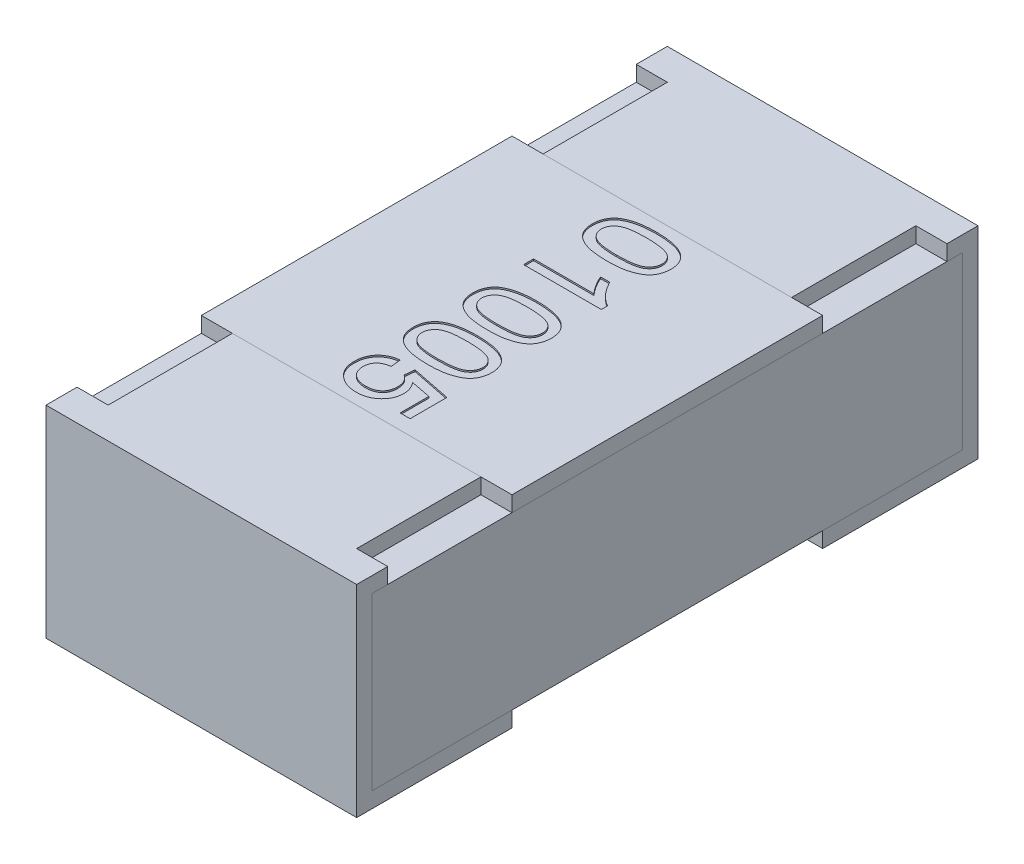
from build123d import *

# Parameters (mm, degrees)
BOSS_EXTRUDE2_DEPTH   = 0.1
BOSS_EXTRUDE2_2_DEPTH = 0.1
BOSS_EXTRUDE3_START   = -0.1
SKETCH5_W             = 0.38
SKETCH5_H             = 0.11
BOSS_EXTRUDE3_DEPTH   = 0.2
SKETCH6_W             = 0.02
SKETCH6_H             = 0.08
CUT_EXTRUDE1_DEPTH    = 0.01
SKETCH7_W             = 0.2
SKETCH7_H             = 0.2
BOSS_EXTRUDE4_DEPTH   = 0.01
TEXT01005_DEPTH       = 0.001


with BuildPart() as part:
    # Sketch4 → Boss-Extrude2 (new, symmetric)
    with BuildSketch(Plane(origin=(0, 0, 0), x_dir=(0, 0, -1), z_dir=(1, 0, 0))):
        Polygon((-0.2, 0.065), (-0.2, -0.065), (-0.1, -0.065), (-0.1, -0.055), (-0.19, -0.055), (-0.19, 0.055), (-0.1, 0.055), (-0.1, 0.065), align=None)
    extrude(amount=BOSS_EXTRUDE2_DEPTH, both=True)


with BuildPart() as body_2:
    # Sketch4 → Boss-Extrude2 2 (new, symmetric)
    with BuildSketch(Plane(origin=(0, 0, 0), x_dir=(0, 0, -1), z_dir=(1, 0, 0))):
        Polygon((0.1, 0.065), (0.2, 0.065), (0.2, -0.065), (0.1, -0.065), (0.1, -0.055), (0.19, -0.055), (0.19, 0.055), (0.1, 0.055), align=None)
    extrude(amount=BOSS_EXTRUDE2_2_DEPTH, both=True)


with BuildPart() as body_3:
    # Sketch5 → Boss-Extrude3 (new body)
    with BuildSketch(Plane(origin=(0, 0, 0), x_dir=(0, 0, -1), z_dir=(1, 0, 0)).offset(BOSS_EXTRUDE3_START)):
        Rectangle(SKETCH5_W, SKETCH5_H)
    extrude(amount=BOSS_EXTRUDE3_DEPTH)


with BuildPart() as cut_extrude1_tool:
    # Sketch6 → Cut-Extrude1 (new body)
    with BuildSketch(Plane(origin=(0, 0.065, 0), x_dir=(1, 0, 0), z_dir=(0, 1, 0))):
        with Locations((-0.09, 0.14)):
            Rectangle(SKETCH6_W, SKETCH6_H)
        with Locations((0.09, 0.14)):
            Rectangle(SKETCH6_W, SKETCH6_H)
        with Locations((0.09, -0.14)):
            Rectangle(SKETCH6_W, SKETCH6_H)
        with Locations((-0.09, -0.14)):
            Rectangle(SKETCH6_W, SKETCH6_H)
    extrude(amount=-CUT_EXTRUDE1_DEPTH)


with BuildPart() as part_1:
    add(part.part)

    # Cut-Extrude1: cut by cut_extrude1_tool
    add(cut_extrude1_tool.part, mode=Mode.SUBTRACT)


with BuildPart() as body_2_1:
    add(body_2.part)

    # Cut-Extrude1: cut by cut_extrude1_tool
    add(cut_extrude1_tool.part, mode=Mode.SUBTRACT)


with BuildPart() as body_4:
    # Sketch7 → Boss-Extrude4 (new body)
    with BuildSketch(Plane(origin=(0, 0.055, 0), x_dir=(1, 0, 0), z_dir=(0, 1, 0))):
        Rectangle(SKETCH7_W, SKETCH7_H)
    extrude(amount=BOSS_EXTRUDE4_DEPTH)

    # PART NUMBER → TEXT01005 (cut)
    with BuildSketch(Plane(origin=(0, 0.065, 0), x_dir=(1, 0, 0), z_dir=(0, 1, 0))):
        with BuildLine():
            add(Edge.make_bspline(
                [(8.8495e-05, 0.092948718), (0.000803041, 0.09294226), (0.002202536, 0.09292961), (0.004250247, 0.092851152), (0.006194875, 0.092714169), (0.008034729, 0.092509693), (0.00977396, 0.092267551), (0.011410096, 0.091952778), (0.012946776, 0.091598571), (0.014382506, 0.091173731), (0.015729255, 0.090706481), (0.016986174, 0.090178088), (0.018145829, 0.08957835), (0.019239713, 0.088961347), (0.020216586, 0.088242997), (0.021138322, 0.087514504), (0.021952307, 0.08670136), (0.022685184, 0.08584224), (0.023331701, 0.084922905), (0.023889621, 0.083948635), (0.024382209, 0.082923069), (0.024753033, 0.08182669), (0.025055332, 0.080682251), (0.025277707, 0.079480944), (0.025408805, 0.078221446), (0.025422219, 0.077360756), (0.02542904, 0.076923077)],
                knots=[0, 0, 0, 0, 1.514715004, 2.966688829, 4.343277319, 5.646155648, 6.890271291, 8.064567311, 9.176982507, 10.231801866, 11.236819303, 12.197732759, 13.118802951, 14.00370591, 14.856056722, 15.686168072, 16.491905873, 17.290274347, 18.077650358, 18.870352107, 19.668187111, 20.485160842, 21.319455353, 22.17593919, 23.072426909, 24, 24, 24, 24], degree=3))
            add(Edge.make_bspline(
                [(0.02542904, 0.076923077), (0.025410145, 0.076280957), (0.025373025, 0.075019485), (0.025070789, 0.073177535), (0.024552489, 0.071442361), (0.023858738, 0.069814235), (0.022961316, 0.068328362), (0.021898424, 0.066984995), (0.020625562, 0.065838411), (0.0191845, 0.064850736), (0.017572378, 0.064003804), (0.015804378, 0.06324619), (0.013873004, 0.062566917), (0.012149052, 0.06206972), (0.010658354, 0.06172114), (0.009426545, 0.061508915), (0.008101495, 0.06131297), (0.006680033, 0.061174081), (0.005168803, 0.061032751), (0.003561213, 0.060962974), (0.001858357, 0.060909724), (0.000689509, 0.060901609), (8.8495e-05, 0.060897436)],
                knots=[0, 0, 0, 0, 1.134508601, 2.228787654, 3.287419779, 4.328790846, 5.347871456, 6.346850563, 7.345149742, 8.363256079, 9.427154287, 10.558404831, 11.760335901, 13.043439251, 13.7276639, 14.464993199, 15.251939769, 16.09452972, 16.988861801, 17.934185368, 18.937772297, 20, 20, 20, 20], degree=3))
            add(Edge.make_bspline(
                [(8.8495e-05, 0.060897436), (-0.0006227, 0.060903979), (-0.00201216, 0.060916762), (-0.004043374, 0.060993624), (-0.005973605, 0.06113708), (-0.007805205, 0.061321944), (-0.009539873, 0.06157084), (-0.011173365, 0.061881931), (-0.012707682, 0.062241242), (-0.014144374, 0.062647851), (-0.015485416, 0.063120912), (-0.016737228, 0.063654462), (-0.017912074, 0.064226585), (-0.018988075, 0.064875528), (-0.019983042, 0.065566691), (-0.020900108, 0.066306531), (-0.021726238, 0.067110372), (-0.022456707, 0.067977512), (-0.023114851, 0.068890284), (-0.023677844, 0.069867085), (-0.024147521, 0.070905631), (-0.024540072, 0.071996665), (-0.024838402, 0.073147429), (-0.025059905, 0.074351926), (-0.025192206, 0.075618016), (-0.025205301, 0.076482055), (-0.025211986, 0.076923077)],
                knots=[0, 0, 0, 0, 1.50892112, 2.947974422, 4.311604492, 5.614840882, 6.853004102, 8.028299315, 9.14166105, 10.195403725, 11.194594867, 12.156325951, 13.08133133, 13.964490992, 14.819271038, 15.650088719, 16.461567135, 17.260614929, 18.05275699, 18.846133239, 19.648095618, 20.468123593, 21.303127994, 22.167306962, 23.06455749, 24, 24, 24, 24], degree=3))
            add(Edge.make_bspline(
                [(-0.025211986, 0.076923077), (-0.025195492, 0.077501295), (-0.025163334, 0.078628662), (-0.024944839, 0.080275097), (-0.024560277, 0.081820365), (-0.024044526, 0.083277498), (-0.023354678, 0.084630119), (-0.022515345, 0.085884684), (-0.021546052, 0.087066404), (-0.020781303, 0.087746674), (-0.020394277, 0.088090946)],
                knots=[0, 0, 0, 0, 1.10322584, 2.150986741, 3.161425019, 4.136713905, 5.093944212, 6.049774532, 7.013026876, 8, 8, 8, 8], degree=3))
            add(Edge.make_bspline(
                [(-0.020394277, 0.088090946), (-0.019822659, 0.088487211), (-0.018643958, 0.089304326), (-0.016634164, 0.090260689), (-0.014421662, 0.091113781), (-0.011963045, 0.091783302), (-0.009277879, 0.092307704), (-0.006360896, 0.092686453), (-0.003213356, 0.092900788), (-0.001036968, 0.092932381), (8.8495e-05, 0.092948718)],
                knots=[0, 0, 0, 0, 0.779365345, 1.607084704, 2.489375761, 3.438383567, 4.461919411, 5.557722155, 6.737039282, 8, 8, 8, 8], degree=3))
        make_face()
        with BuildLine():
            add(Edge.make_bspline(
                [(0.000108527, 0.086538462), (-0.000853155, 0.086532097), (-0.002694026, 0.086519913), (-0.005324029, 0.086392622), (-0.007696651, 0.086173496), (-0.009808606, 0.085883797), (-0.011662752, 0.085501277), (-0.013254364, 0.085020978), (-0.014602544, 0.084479567), (-0.015690582, 0.083809581), (-0.016577493, 0.08307602), (-0.017340264, 0.082318668), (-0.017988602, 0.081519709), (-0.018529184, 0.080684353), (-0.018938478, 0.079799642), (-0.019235134, 0.078875248), (-0.019405855, 0.07791097), (-0.019430385, 0.077254254), (-0.019442755, 0.076923077)],
                knots=[0, 0, 0, 0, 1.89448813, 3.626469325, 5.185477471, 6.587276848, 7.82441448, 8.910550357, 9.859733512, 10.6775885, 11.416198291, 12.123144072, 12.791880183, 13.439617036, 14.078171869, 14.70637855, 15.347637704, 16, 16, 16, 16], degree=3))
            add(Edge.make_bspline(
                [(-0.019442755, 0.076923077), (-0.019430115, 0.076591983), (-0.019405049, 0.075935431), (-0.019238092, 0.074968925), (-0.018926164, 0.074048128), (-0.018518317, 0.073164736), (-0.017990056, 0.072323309), (-0.017339269, 0.071528273), (-0.01657695, 0.070766932), (-0.015679731, 0.070036666), (-0.014586662, 0.069371784), (-0.01323958, 0.068820217), (-0.011645182, 0.068347403), (-0.009791981, 0.067962784), (-0.007683364, 0.06767189), (-0.005317323, 0.067454089), (-0.002690704, 0.067325946), (-0.000853159, 0.067313964), (0.000108527, 0.067307692)],
                knots=[0, 0, 0, 0, 0.652509534, 1.29391342, 1.924290653, 2.562989607, 3.207355802, 3.876242846, 4.583348185, 5.32723334, 6.150888545, 7.094226006, 8.186903555, 9.424320409, 10.81992305, 12.379283064, 14.105084285, 16, 16, 16, 16], degree=3))
            add(Edge.make_bspline(
                [(0.000108527, 0.067307692), (0.001050204, 0.067313763), (0.002854421, 0.067325393), (0.005433756, 0.067456842), (0.007766557, 0.067662829), (0.009854958, 0.067944602), (0.011696748, 0.06831903), (0.013295668, 0.068773305), (0.014648865, 0.0693142), (0.01576821, 0.06995868), (0.016692192, 0.07067326), (0.017476382, 0.071432482), (0.018163594, 0.072221654), (0.018701695, 0.073085875), (0.019143015, 0.073988405), (0.019438449, 0.074948591), (0.019628057, 0.075954035), (0.01964907, 0.076641738), (0.019659809, 0.076993189)],
                knots=[0, 0, 0, 0, 1.850145643, 3.544809038, 5.072983816, 6.450691362, 7.683229814, 8.76276662, 9.712991103, 10.538891656, 11.292051756, 12.001912283, 12.681449089, 13.342071824, 13.996410874, 14.649960216, 15.310061595, 16, 16, 16, 16], degree=3))
            add(Edge.make_bspline(
                [(0.019659809, 0.076993189), (0.019651118, 0.077324345), (0.019633979, 0.077977342), (0.019470391, 0.078933415), (0.019196836, 0.079839474), (0.018826279, 0.0807059), (0.018327583, 0.081511063), (0.01774532, 0.082286893), (0.017035896, 0.082997054), (0.016505543, 0.08342499), (0.016234329, 0.08364383)],
                knots=[0, 0, 0, 0, 1.021318143, 2.013908504, 2.982026795, 3.937174072, 4.91255697, 5.897578595, 6.924855925, 8, 8, 8, 8], degree=3))
            add(Edge.make_bspline(
                [(0.016234329, 0.08364383), (0.015835999, 0.08388208), (0.01499481, 0.084385213), (0.01353279, 0.084948191), (0.011861979, 0.085445502), (0.009956671, 0.085854955), (0.007820135, 0.086151165), (0.00545485, 0.086385011), (0.002857516, 0.086506486), (0.001050139, 0.086527509), (0.000108527, 0.086538462)],
                knots=[0, 0, 0, 0, 0.671104906, 1.417232262, 2.260109084, 3.195198885, 4.23592645, 5.382417421, 6.636286093, 8, 8, 8, 8], degree=3))
        make_face(mode=Mode.SUBTRACT)
        with BuildLine():
            Line((-0.02457096, 0.032051282), (-0.02457096, 0.038461538))
            Line((-0.02457096, 0.038461538), (0.01439138, 0.038461538))
            add(Edge.make_bspline(
                [(0.01439138, 0.038461538), (0.014035458, 0.038830663), (0.013295714, 0.039597847), (0.012248134, 0.040894257), (0.011190981, 0.042340899), (0.010160607, 0.043913775), (0.009209622, 0.045529431), (0.008341859, 0.047086025), (0.007611299, 0.048561816), (0.007211452, 0.049533661), (0.007019585, 0.05)],
                knots=[0, 0, 0, 0, 0.89334793, 1.85672577, 2.901900665, 4.015525414, 5.132247281, 6.168817625, 7.121308293, 8, 8, 8, 8], degree=3))
            Line((0.007019585, 0.05), (0.01292904, 0.05))
            add(Edge.make_bspline(
                [(0.01292904, 0.05), (0.013341567, 0.04919898), (0.014154633, 0.047620217), (0.01555891, 0.045389766), (0.017081204, 0.0433074), (0.018721178, 0.041407591), (0.020397526, 0.039704533), (0.022089027, 0.038269341), (0.023733678, 0.037068464), (0.02488064, 0.036465961), (0.02542904, 0.036177885)],
                knots=[0, 0, 0, 0, 1.141258006, 2.249351951, 3.335817539, 4.406819942, 5.426913362, 6.360259544, 7.215985427, 8, 8, 8, 8], degree=3))
            Line((0.02542904, 0.036177885), (0.02542904, 0.032051282))
            Line((0.02542904, 0.032051282), (-0.02457096, 0.032051282))
        make_face()
        with BuildLine():
            add(Edge.make_bspline(
                [(8.8495e-05, 0.016025641), (0.000803041, 0.016019183), (0.002202536, 0.016006534), (0.004250247, 0.015928075), (0.006194875, 0.015791092), (0.008034729, 0.015586616), (0.00977396, 0.015344474), (0.011410096, 0.015029701), (0.012946776, 0.014675494), (0.014382506, 0.014250654), (0.015729255, 0.013783404), (0.016986174, 0.013255012), (0.018145829, 0.012655273), (0.019239713, 0.01203827), (0.020216586, 0.01131992), (0.021138322, 0.010591427), (0.021952307, 0.009778283), (0.022685184, 0.008919163), (0.023331701, 0.007999828), (0.023889621, 0.007025559), (0.024382209, 0.005999992), (0.024753033, 0.004903613), (0.025055332, 0.003759174), (0.025277707, 0.002557867), (0.025408805, 0.001298369), (0.025422219, 0.000437679), (0.02542904, 0)],
                knots=[0, 0, 0, 0, 1.514715004, 2.966688829, 4.343277319, 5.646155648, 6.890271291, 8.064567311, 9.176982507, 10.231801866, 11.236819303, 12.197732759, 13.118802951, 14.00370591, 14.856056722, 15.686168072, 16.491905873, 17.290274347, 18.077650358, 18.870352107, 19.668187111, 20.485160842, 21.319455353, 22.17593919, 23.072426909, 24, 24, 24, 24], degree=3))
            add(Edge.make_bspline(
                [(0.02542904, 0), (0.025410145, -0.00064212), (0.025373025, -0.001903592), (0.025070789, -0.003745542), (0.024552489, -0.005480716), (0.023858738, -0.007108842), (0.022961316, -0.008594715), (0.021898424, -0.009938082), (0.020625562, -0.011084666), (0.0191845, -0.012072341), (0.017572378, -0.012919273), (0.015804378, -0.013676887), (0.013873004, -0.014356159), (0.012149052, -0.014853357), (0.010658354, -0.015201937), (0.009426545, -0.015414162), (0.008101495, -0.015610107), (0.006680033, -0.015748996), (0.005168803, -0.015890326), (0.003561213, -0.015960103), (0.001858357, -0.016013353), (0.000689509, -0.016021468), (8.8495e-05, -0.016025641)],
                knots=[0, 0, 0, 0, 1.134508601, 2.228787654, 3.287419779, 4.328790846, 5.347871456, 6.346850563, 7.345149742, 8.363256079, 9.427154287, 10.558404831, 11.760335901, 13.043439251, 13.7276639, 14.464993199, 15.251939769, 16.09452972, 16.988861801, 17.934185368, 18.937772297, 20, 20, 20, 20], degree=3))
            add(Edge.make_bspline(
                [(8.8495e-05, -0.016025641), (-0.0006227, -0.016019098), (-0.00201216, -0.016006315), (-0.004043374, -0.015929453), (-0.005973605, -0.015785997), (-0.007805205, -0.015601133), (-0.009539873, -0.015352237), (-0.011173365, -0.015041146), (-0.012707682, -0.014681835), (-0.014144374, -0.014275226), (-0.015485416, -0.013802165), (-0.016737228, -0.013268615), (-0.017912074, -0.012696492), (-0.018988075, -0.012047549), (-0.019983042, -0.011356386), (-0.020900108, -0.010616546), (-0.021726238, -0.009812705), (-0.022456707, -0.008945565), (-0.023114851, -0.008032793), (-0.023677844, -0.007055991), (-0.024147521, -0.006017446), (-0.024540072, -0.004926412), (-0.024838402, -0.003775648), (-0.025059905, -0.00257115), (-0.025192206, -0.001305061), (-0.025205301, -0.000441022), (-0.025211986, 0)],
                knots=[0, 0, 0, 0, 1.50892112, 2.947974422, 4.311604492, 5.614840882, 6.853004102, 8.028299315, 9.14166105, 10.195403725, 11.194594867, 12.156325951, 13.08133133, 13.964490992, 14.819271038, 15.650088719, 16.461567135, 17.260614929, 18.05275699, 18.846133239, 19.648095618, 20.468123593, 21.303127994, 22.167306962, 23.06455749, 24, 24, 24, 24], degree=3))
            add(Edge.make_bspline(
                [(-0.025211986, 0), (-0.025195492, 0.000578218), (-0.025163334, 0.001705585), (-0.024944839, 0.003352021), (-0.024560277, 0.004897288), (-0.024044526, 0.006354421), (-0.023354678, 0.007707042), (-0.022515345, 0.008961607), (-0.021546052, 0.010143327), (-0.020781303, 0.010823597), (-0.020394277, 0.011167869)],
                knots=[0, 0, 0, 0, 1.10322584, 2.150986741, 3.161425019, 4.136713905, 5.093944212, 6.049774532, 7.013026876, 8, 8, 8, 8], degree=3))
            add(Edge.make_bspline(
                [(-0.020394277, 0.011167869), (-0.019822659, 0.011564134), (-0.018643958, 0.012381249), (-0.016634164, 0.013337612), (-0.014421662, 0.014190704), (-0.011963045, 0.014860225), (-0.009277879, 0.015384627), (-0.006360896, 0.015763377), (-0.003213356, 0.015977711), (-0.001036968, 0.016009304), (8.8495e-05, 0.016025641)],
                knots=[0, 0, 0, 0, 0.779365345, 1.607084704, 2.489375761, 3.438383567, 4.461919411, 5.557722155, 6.737039282, 8, 8, 8, 8], degree=3))
        make_face()
        with BuildLine():
            add(Edge.make_bspline(
                [(0.000108527, 0.009615385), (-0.000853155, 0.00960902), (-0.002694026, 0.009596836), (-0.005324029, 0.009469545), (-0.007696651, 0.009250419), (-0.009808606, 0.00896072), (-0.011662752, 0.0085782), (-0.013254364, 0.008097901), (-0.014602544, 0.00755649), (-0.015690582, 0.006886504), (-0.016577493, 0.006152943), (-0.017340264, 0.005395592), (-0.017988602, 0.004596632), (-0.018529184, 0.003761276), (-0.018938478, 0.002876565), (-0.019235134, 0.001952171), (-0.019405855, 0.000987893), (-0.019430385, 0.000331177), (-0.019442755, 0)],
                knots=[0, 0, 0, 0, 1.89448813, 3.626469325, 5.185477471, 6.587276848, 7.82441448, 8.910550357, 9.859733512, 10.6775885, 11.416198291, 12.123144072, 12.791880183, 13.439617036, 14.078171869, 14.70637855, 15.347637704, 16, 16, 16, 16], degree=3))
            add(Edge.make_bspline(
                [(-0.019442755, 0), (-0.019430115, -0.000331094), (-0.019405049, -0.000987646), (-0.019238092, -0.001954151), (-0.018926164, -0.002874949), (-0.018518317, -0.003758341), (-0.017990056, -0.004599768), (-0.017339269, -0.005394804), (-0.01657695, -0.006156145), (-0.015679731, -0.006886411), (-0.014586662, -0.007551293), (-0.01323958, -0.00810286), (-0.011645182, -0.008575674), (-0.009791981, -0.008960293), (-0.007683364, -0.009251187), (-0.005317323, -0.009468988), (-0.002690704, -0.009597131), (-0.000853159, -0.009609113), (0.000108527, -0.009615385)],
                knots=[0, 0, 0, 0, 0.652509534, 1.29391342, 1.924290653, 2.562989607, 3.207355802, 3.876242846, 4.583348185, 5.32723334, 6.150888545, 7.094226006, 8.186903555, 9.424320409, 10.81992305, 12.379283064, 14.105084285, 16, 16, 16, 16], degree=3))
            add(Edge.make_bspline(
                [(0.000108527, -0.009615385), (0.001050204, -0.009609314), (0.002854421, -0.009597684), (0.005433756, -0.009466235), (0.007766557, -0.009260248), (0.009854958, -0.008978475), (0.011696748, -0.008604047), (0.013295668, -0.008149772), (0.014648865, -0.007608877), (0.01576821, -0.006964396), (0.016692192, -0.006249817), (0.017476382, -0.005490595), (0.018163594, -0.004701423), (0.018701695, -0.003837202), (0.019143015, -0.002934672), (0.019438449, -0.001974486), (0.019628057, -0.000969042), (0.01964907, -0.000281339), (0.019659809, 7.0112e-05)],
                knots=[0, 0, 0, 0, 1.850145643, 3.544809038, 5.072983816, 6.450691362, 7.683229814, 8.76276662, 9.712991103, 10.538891656, 11.292051756, 12.001912283, 12.681449089, 13.342071824, 13.996410874, 14.649960216, 15.310061595, 16, 16, 16, 16], degree=3))
            add(Edge.make_bspline(
                [(0.019659809, 7.0112e-05), (0.019651118, 0.000401268), (0.019633979, 0.001054265), (0.019470391, 0.002010338), (0.019196836, 0.002916397), (0.018826279, 0.003782823), (0.018327583, 0.004587986), (0.01774532, 0.005363816), (0.017035896, 0.006073977), (0.016505543, 0.006501913), (0.016234329, 0.006720753)],
                knots=[0, 0, 0, 0, 1.021318143, 2.013908504, 2.982026795, 3.937174072, 4.91255697, 5.897578595, 6.924855925, 8, 8, 8, 8], degree=3))
            add(Edge.make_bspline(
                [(0.016234329, 0.006720753), (0.015835999, 0.006959003), (0.01499481, 0.007462137), (0.01353279, 0.008025114), (0.011861979, 0.008522425), (0.009956671, 0.008931878), (0.007820135, 0.009228088), (0.00545485, 0.009461934), (0.002857516, 0.009583409), (0.001050139, 0.009604432), (0.000108527, 0.009615385)],
                knots=[0, 0, 0, 0, 0.671104906, 1.417232262, 2.260109084, 3.195198885, 4.23592645, 5.382417421, 6.636286093, 8, 8, 8, 8], degree=3))
        make_face(mode=Mode.SUBTRACT)
        with BuildLine():
            add(Edge.make_bspline(
                [(8.8495e-05, -0.022435897), (0.000803041, -0.022442356), (0.002202536, -0.022455005), (0.004250247, -0.022533463), (0.006194875, -0.022670446), (0.008034729, -0.022874922), (0.00977396, -0.023117064), (0.011410096, -0.023431837), (0.012946776, -0.023786044), (0.014382506, -0.024210885), (0.015729255, -0.024678134), (0.016986174, -0.025206527), (0.018145829, -0.025806265), (0.019239713, -0.026423269), (0.020216586, -0.027141619), (0.021138322, -0.027870112), (0.021952307, -0.028683255), (0.022685184, -0.029542375), (0.023331701, -0.03046171), (0.023889621, -0.03143598), (0.024382209, -0.032461546), (0.024753033, -0.033557925), (0.025055332, -0.034702365), (0.025277707, -0.035903671), (0.025408805, -0.037163169), (0.025422219, -0.03802386), (0.02542904, -0.038461538)],
                knots=[0, 0, 0, 0, 1.514715004, 2.966688829, 4.343277319, 5.646155648, 6.890271291, 8.064567311, 9.176982507, 10.231801866, 11.236819303, 12.197732759, 13.118802951, 14.00370591, 14.856056722, 15.686168072, 16.491905873, 17.290274347, 18.077650358, 18.870352107, 19.668187111, 20.485160842, 21.319455353, 22.17593919, 23.072426909, 24, 24, 24, 24], degree=3))
            add(Edge.make_bspline(
                [(0.02542904, -0.038461538), (0.025410145, -0.039103659), (0.025373025, -0.04036513), (0.025070789, -0.042207081), (0.024552489, -0.043942255), (0.023858738, -0.045570381), (0.022961316, -0.047056253), (0.021898424, -0.048399621), (0.020625562, -0.049546205), (0.0191845, -0.05053388), (0.017572378, -0.051380811), (0.015804378, -0.052138426), (0.013873004, -0.052817698), (0.012149052, -0.053314896), (0.010658354, -0.053663475), (0.009426545, -0.0538757), (0.008101495, -0.054071646), (0.006680033, -0.054210534), (0.005168803, -0.054351865), (0.003561213, -0.054421641), (0.001858357, -0.054474891), (0.000689509, -0.054483007), (8.8495e-05, -0.054487179)],
                knots=[0, 0, 0, 0, 1.134508601, 2.228787654, 3.287419779, 4.328790846, 5.347871456, 6.346850563, 7.345149742, 8.363256079, 9.427154287, 10.558404831, 11.760335901, 13.043439251, 13.7276639, 14.464993199, 15.251939769, 16.09452972, 16.988861801, 17.934185368, 18.937772297, 20, 20, 20, 20], degree=3))
            add(Edge.make_bspline(
                [(8.8495e-05, -0.054487179), (-0.0006227, -0.054480637), (-0.00201216, -0.054467854), (-0.004043374, -0.054390992), (-0.005973605, -0.054247536), (-0.007805205, -0.054062672), (-0.009539873, -0.053813776), (-0.011173365, -0.053502685), (-0.012707682, -0.053143374), (-0.014144374, -0.052736764), (-0.015485416, -0.052263704), (-0.016737228, -0.051730154), (-0.017912074, -0.051158031), (-0.018988075, -0.050509088), (-0.019983042, -0.049817925), (-0.020900108, -0.049078085), (-0.021726238, -0.048274243), (-0.022456707, -0.047407104), (-0.023114851, -0.046494332), (-0.023677844, -0.04551753), (-0.024147521, -0.044478984), (-0.024540072, -0.04338795), (-0.024838402, -0.042237187), (-0.025059905, -0.041032689), (-0.025192206, -0.039766599), (-0.025205301, -0.038902561), (-0.025211986, -0.038461538)],
                knots=[0, 0, 0, 0, 1.50892112, 2.947974422, 4.311604492, 5.614840882, 6.853004102, 8.028299315, 9.14166105, 10.195403725, 11.194594867, 12.156325951, 13.08133133, 13.964490992, 14.819271038, 15.650088719, 16.461567135, 17.260614929, 18.05275699, 18.846133239, 19.648095618, 20.468123593, 21.303127994, 22.167306962, 23.06455749, 24, 24, 24, 24], degree=3))
            add(Edge.make_bspline(
                [(-0.025211986, -0.038461538), (-0.025195492, -0.03788332), (-0.025163334, -0.036755954), (-0.024944839, -0.035109518), (-0.024560277, -0.03356425), (-0.024044526, -0.032107117), (-0.023354678, -0.030754497), (-0.022515345, -0.029499932), (-0.021546052, -0.028318212), (-0.020781303, -0.027637942), (-0.020394277, -0.02729367)],
                knots=[0, 0, 0, 0, 1.10322584, 2.150986741, 3.161425019, 4.136713905, 5.093944212, 6.049774532, 7.013026876, 8, 8, 8, 8], degree=3))
            add(Edge.make_bspline(
                [(-0.020394277, -0.02729367), (-0.019822659, -0.026897405), (-0.018643958, -0.026080289), (-0.016634164, -0.025123927), (-0.014421662, -0.024270834), (-0.011963045, -0.023601313), (-0.009277879, -0.023076911), (-0.006360896, -0.022698162), (-0.003213356, -0.022483827), (-0.001036968, -0.022452235), (8.8495e-05, -0.022435897)],
                knots=[0, 0, 0, 0, 0.779365345, 1.607084704, 2.489375761, 3.438383567, 4.461919411, 5.557722155, 6.737039282, 8, 8, 8, 8], degree=3))
        make_face()
        with BuildLine():
            add(Edge.make_bspline(
                [(0.000108527, -0.028846154), (-0.000853155, -0.028852519), (-0.002694026, -0.028864702), (-0.005324029, -0.028991993), (-0.007696651, -0.029211119), (-0.009808606, -0.029500818), (-0.011662752, -0.029883338), (-0.013254364, -0.030363637), (-0.014602544, -0.030905049), (-0.015690582, -0.031575035), (-0.016577493, -0.032308596), (-0.017340264, -0.033065947), (-0.017988602, -0.033864907), (-0.018529184, -0.034700262), (-0.018938478, -0.035584974), (-0.019235134, -0.036509368), (-0.019405855, -0.037473645), (-0.019430385, -0.038130362), (-0.019442755, -0.038461538)],
                knots=[0, 0, 0, 0, 1.89448813, 3.626469325, 5.185477471, 6.587276848, 7.82441448, 8.910550357, 9.859733512, 10.6775885, 11.416198291, 12.123144072, 12.791880183, 13.439617036, 14.078171869, 14.70637855, 15.347637704, 16, 16, 16, 16], degree=3))
            add(Edge.make_bspline(
                [(-0.019442755, -0.038461538), (-0.019430115, -0.038792632), (-0.019405049, -0.039449184), (-0.019238092, -0.04041569), (-0.018926164, -0.041336487), (-0.018518317, -0.04221988), (-0.017990056, -0.043061307), (-0.017339269, -0.043856343), (-0.01657695, -0.044617684), (-0.015679731, -0.045347949), (-0.014586662, -0.046012831), (-0.01323958, -0.046564398), (-0.011645182, -0.047037212), (-0.009791981, -0.047421831), (-0.007683364, -0.047712725), (-0.005317323, -0.047930526), (-0.002690704, -0.048058669), (-0.000853159, -0.048070652), (0.000108527, -0.048076923)],
                knots=[0, 0, 0, 0, 0.652509534, 1.29391342, 1.924290653, 2.562989607, 3.207355802, 3.876242846, 4.583348185, 5.32723334, 6.150888545, 7.094226006, 8.186903555, 9.424320409, 10.81992305, 12.379283064, 14.105084285, 16, 16, 16, 16], degree=3))
            add(Edge.make_bspline(
                [(0.000108527, -0.048076923), (0.001050204, -0.048070853), (0.002854421, -0.048059222), (0.005433756, -0.047927773), (0.007766557, -0.047721786), (0.009854958, -0.047440014), (0.011696748, -0.047065585), (0.013295668, -0.046611311), (0.014648865, -0.046070415), (0.01576821, -0.045425935), (0.016692192, -0.044711356), (0.017476382, -0.043952134), (0.018163594, -0.043162961), (0.018701695, -0.04229874), (0.019143015, -0.041396211), (0.019438449, -0.040436025), (0.019628057, -0.03943058), (0.01964907, -0.038742877), (0.019659809, -0.038391426)],
                knots=[0, 0, 0, 0, 1.850145643, 3.544809038, 5.072983816, 6.450691362, 7.683229814, 8.76276662, 9.712991103, 10.538891656, 11.292051756, 12.001912283, 12.681449089, 13.342071824, 13.996410874, 14.649960216, 15.310061595, 16, 16, 16, 16], degree=3))
            add(Edge.make_bspline(
                [(0.019659809, -0.038391426), (0.019651118, -0.03806027), (0.019633979, -0.037407273), (0.019470391, -0.0364512), (0.019196836, -0.035545141), (0.018826279, -0.034678715), (0.018327583, -0.033873553), (0.01774532, -0.033097723), (0.017035896, -0.032387562), (0.016505543, -0.031959625), (0.016234329, -0.031740785)],
                knots=[0, 0, 0, 0, 1.021318143, 2.013908504, 2.982026795, 3.937174072, 4.91255697, 5.897578595, 6.924855925, 8, 8, 8, 8], degree=3))
            add(Edge.make_bspline(
                [(0.016234329, -0.031740785), (0.015835999, -0.031502535), (0.01499481, -0.030999402), (0.01353279, -0.030436425), (0.011861979, -0.029939113), (0.009956671, -0.029529661), (0.007820135, -0.02923345), (0.00545485, -0.028999604), (0.002857516, -0.02887813), (0.001050139, -0.028857106), (0.000108527, -0.028846154)],
                knots=[0, 0, 0, 0, 0.671104906, 1.417232262, 2.260109084, 3.195198885, 4.23592645, 5.382417421, 6.636286093, 8, 8, 8, 8], degree=3))
        make_face(mode=Mode.SUBTRACT)
        with BuildLine():
            Line((-0.011109421, -0.060897436), (-0.010468396, -0.067307692))
            add(Edge.make_bspline(
                [(-0.010468396, -0.067307692), (-0.010829579, -0.067371164), (-0.011532135, -0.067494626), (-0.012549107, -0.067729897), (-0.013493902, -0.068035447), (-0.014374703, -0.068378765), (-0.015182196, -0.068786858), (-0.015929132, -0.069229029), (-0.016588997, -0.06975048), (-0.017196301, -0.070298715), (-0.017731444, -0.070900445), (-0.018182588, -0.071561477), (-0.018576183, -0.072263366), (-0.018898442, -0.073014662), (-0.019134318, -0.073816516), (-0.019320856, -0.074658723), (-0.019414851, -0.075552127), (-0.019433335, -0.07616169), (-0.019442755, -0.076472356)],
                knots=[0, 0, 0, 0, 1.237781394, 2.407677316, 3.51963579, 4.58689595, 5.594855907, 6.570874, 7.510833816, 8.428091223, 9.330271693, 10.221190844, 11.124215526, 12.043132878, 12.973586933, 13.941700858, 14.950982896, 16, 16, 16, 16], degree=3))
            add(Edge.make_bspline(
                [(-0.019442755, -0.076472356), (-0.019433546, -0.076853473), (-0.019415538, -0.077598764), (-0.01926323, -0.078683021), (-0.019012092, -0.079707189), (-0.018660643, -0.080666369), (-0.018223575, -0.081571804), (-0.017657652, -0.082393458), (-0.017021498, -0.083176131), (-0.01626308, -0.083869458), (-0.015437416, -0.084500581), (-0.014536168, -0.085045287), (-0.013571987, -0.085503853), (-0.012545056, -0.085889915), (-0.011449511, -0.086174994), (-0.010291178, -0.086384692), (-0.00906932, -0.08651931), (-0.008231842, -0.086531987), (-0.007804133, -0.086538462)],
                knots=[0, 0, 0, 0, 1.052816602, 2.058828735, 3.018813999, 3.961574988, 4.877590722, 5.788574389, 6.712363302, 7.658909047, 8.620312049, 9.580784896, 10.562948504, 11.56722449, 12.607883026, 13.686460295, 14.818448981, 16, 16, 16, 16], degree=3))
            add(Edge.make_bspline(
                [(-0.007804133, -0.086538462), (-0.007396532, -0.086531103), (-0.006602837, -0.086516774), (-0.005447086, -0.0863961), (-0.00436033, -0.086192509), (-0.003330591, -0.085929081), (-0.00237396, -0.085565979), (-0.001476568, -0.08513532), (-0.000657459, -0.084607744), (0.00010887, -0.084020781), (0.000795854, -0.083350395), (0.001375924, -0.08258753), (0.001883603, -0.081762112), (0.002295299, -0.080857516), (0.002601174, -0.07987321), (0.002836517, -0.078818975), (0.002960297, -0.077683871), (0.002981998, -0.076903301), (0.002993143, -0.076502404)],
                knots=[0, 0, 0, 0, 1.165854935, 2.270189951, 3.319242023, 4.32700288, 5.306253956, 6.24172124, 7.169108591, 8.088047231, 8.999810445, 9.905349262, 10.822648491, 11.767237767, 12.739852311, 13.766490849, 14.852878837, 16, 16, 16, 16], degree=3))
            add(Edge.make_bspline(
                [(0.002993143, -0.076502404), (0.002978179, -0.076003987), (0.002949383, -0.075044842), (0.002718518, -0.073670057), (0.002332917, -0.072421137), (0.001769153, -0.071310464), (0.001092206, -0.070315978), (0.000326627, -0.069419329), (-0.000527541, -0.068613263), (-0.001170613, -0.068171098), (-0.001494037, -0.067948718)],
                knots=[0, 0, 0, 0, 1.182839217, 2.276233246, 3.299105702, 4.274010162, 5.221622004, 6.149363738, 7.06924902, 8, 8, 8, 8], degree=3))
            Line((-0.001494037, -0.067948718), (-0.000853011, -0.061538462))
            Line((-0.000853011, -0.061538462), (0.024788014, -0.066666667))
            Line((0.024788014, -0.066666667), (0.024788014, -0.090384615))
            Line((0.024788014, -0.090384615), (0.018377758, -0.090384615))
            Line((0.018377758, -0.090384615), (0.018377758, -0.071905048))
            Line((0.018377758, -0.071905048), (0.005427037, -0.069360978))
            add(Edge.make_bspline(
                [(0.005427037, -0.069360978), (0.00569242, -0.069714694), (0.006213589, -0.070409338), (0.006896649, -0.071492584), (0.007468525, -0.072589634), (0.007947213, -0.073694719), (0.008307436, -0.074823159), (0.008565025, -0.07596266), (0.008736859, -0.077114862), (0.008753844, -0.077887345), (0.008762373, -0.07827524)],
                knots=[0, 0, 0, 0, 1.093799738, 2.148049664, 3.164132611, 4.152263193, 5.124065093, 6.089950765, 7.040884846, 8, 8, 8, 8], degree=3))
            add(Edge.make_bspline(
                [(0.008762373, -0.07827524), (0.008749146, -0.078780075), (0.008723099, -0.079774217), (0.008509087, -0.081239119), (0.00814579, -0.082639814), (0.007656476, -0.083987279), (0.007007825, -0.085263779), (0.006222381, -0.086482124), (0.005293972, -0.087637854), (0.004238953, -0.088722659), (0.003072824, -0.089710656), (0.001814655, -0.090576563), (0.000473253, -0.091313311), (-0.000949833, -0.091913693), (-0.002457141, -0.092376827), (-0.004040249, -0.092702252), (-0.005705356, -0.09290908), (-0.00684197, -0.092935302), (-0.007423524, -0.092948718)],
                knots=[0, 0, 0, 0, 0.992032132, 1.95355186, 2.902219785, 3.832411796, 4.765723908, 5.710502202, 6.67700341, 7.674814608, 8.68064359, 9.676380783, 10.672053094, 11.683731334, 12.707113005, 13.766394796, 14.857166291, 16, 16, 16, 16], degree=3))
            add(Edge.make_bspline(
                [(-0.007423524, -0.092948718), (-0.007978248, -0.092937473), (-0.009073987, -0.092915261), (-0.010688218, -0.092730015), (-0.012246626, -0.092432737), (-0.013742006, -0.092007407), (-0.015187585, -0.091479586), (-0.016565535, -0.090810851), (-0.017903212, -0.090046282), (-0.018727445, -0.089431839), (-0.019142274, -0.089122596)],
                knots=[0, 0, 0, 0, 1.059762356, 2.093333049, 3.100576568, 4.08823236, 5.061210495, 6.037154334, 7.012117566, 8, 8, 8, 8], degree=3))
            add(Edge.make_bspline(
                [(-0.019142274, -0.089122596), (-0.019626549, -0.088729831), (-0.020579169, -0.087957218), (-0.021815614, -0.086619449), (-0.022866421, -0.085181328), (-0.023720126, -0.083634296), (-0.02440615, -0.081988741), (-0.024862674, -0.080224445), (-0.025169247, -0.078362729), (-0.025197543, -0.077084625), (-0.025211986, -0.076432292)],
                knots=[0, 0, 0, 0, 1.023140956, 2.012628108, 2.982342558, 3.942221589, 4.908720554, 5.902469194, 6.929439212, 8, 8, 8, 8], degree=3))
            add(Edge.make_bspline(
                [(-0.025211986, -0.076432292), (-0.02520107, -0.075894221), (-0.025179717, -0.074841647), (-0.024994111, -0.073300482), (-0.024698072, -0.071834686), (-0.024273676, -0.070443641), (-0.023736662, -0.069123732), (-0.023058558, -0.067890628), (-0.022273239, -0.066727946), (-0.021370936, -0.065650697), (-0.020375303, -0.064656169), (-0.019276754, -0.063786275), (-0.018105625, -0.06302127), (-0.016865379, -0.062351018), (-0.015531593, -0.061829257), (-0.01413103, -0.061392419), (-0.012649864, -0.061068491), (-0.011628286, -0.060955052), (-0.011109421, -0.060897436)],
                knots=[0, 0, 0, 0, 1.108944452, 2.169317946, 3.195242625, 4.188124799, 5.163410716, 6.127483692, 7.083934052, 8.051587763, 9.020146818, 9.980082967, 10.934624366, 11.901494393, 12.880562006, 13.882043602, 14.924278547, 16, 16, 16, 16], degree=3))
        make_face()
    extrude(amount=-TEXT01005_DEPTH, mode=Mode.SUBTRACT)


solid = Compound([body_3.part, part_1.part, body_2_1.part, body_4.part])
